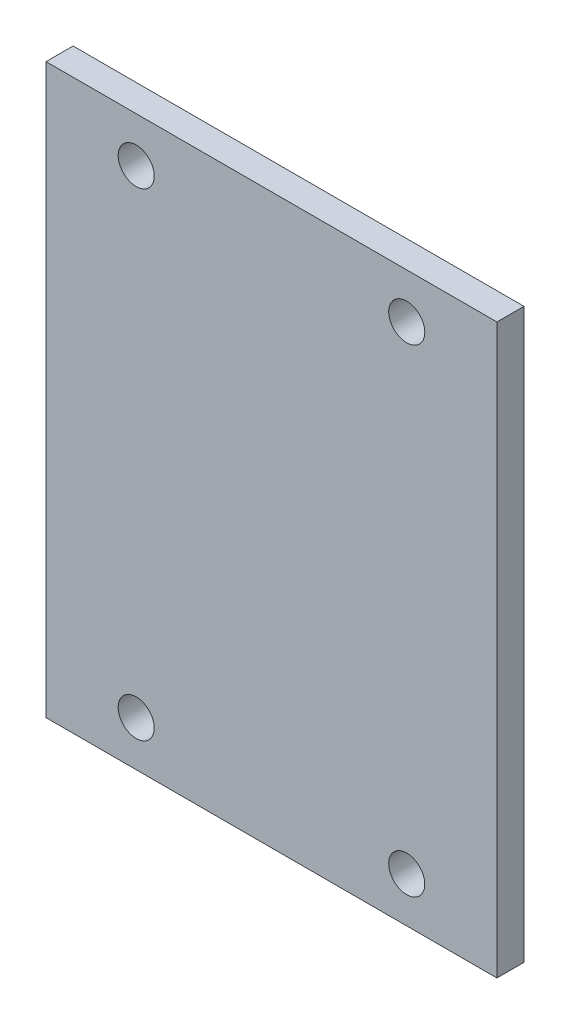
from build123d import *

# Parameters (mm, degrees)
CROQUIS1_W              = 50
CROQUIS1_H              = 63
CROQUIS1_R              = 2
SALIENTE_EXTRUIR1_DEPTH = 3


with BuildPart() as part:
    # Croquis1 → Saliente-Extruir1 (new body)
    with BuildSketch(Plane.XY):
        Rectangle(CROQUIS1_W, CROQUIS1_H)
        with Locations((-15, -26.5)):
            Circle(CROQUIS1_R, mode=Mode.SUBTRACT)
        with Locations((-15, 26.5)):
            Circle(CROQUIS1_R, mode=Mode.SUBTRACT)
        with Locations((15, -26.5)):
            Circle(CROQUIS1_R, mode=Mode.SUBTRACT)
        with Locations((15, 26.5)):
            Circle(CROQUIS1_R, mode=Mode.SUBTRACT)
    extrude(amount=SALIENTE_EXTRUIR1_DEPTH)


solid = part.part
